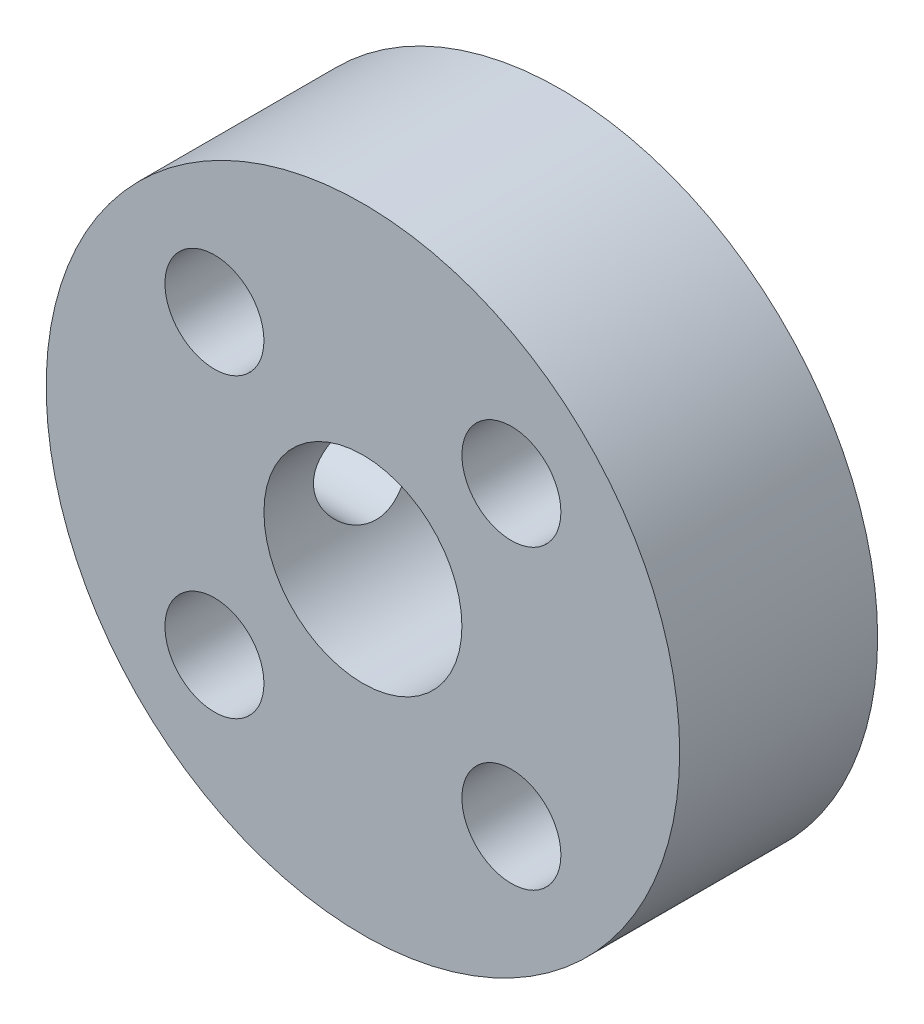
from build123d import *

# Parameters (mm, degrees)
SKETCH1_R           = 20.32
SKETCH1_R_2         = 3.175
SKETCH1_R_3         = 6.35
BOSS_EXTRUDE1_DEPTH = 12.7
SKETCH2_R           = 3.175
CUT_EXTRUDE1_DEPTH  = 21.32


with BuildPart() as part:
    # Sketch1 → Boss-Extrude1 (new body)
    with BuildSketch(Plane.XY):
        Circle(SKETCH1_R)
        with Locations((-9.525, -9.525)):
            Circle(SKETCH1_R_2, mode=Mode.SUBTRACT)
        with Locations((9.525, -9.525)):
            Circle(SKETCH1_R_2, mode=Mode.SUBTRACT)
        with Locations((9.525, 9.525)):
            Circle(SKETCH1_R_2, mode=Mode.SUBTRACT)
        with Locations((-9.525, 9.525)):
            Circle(SKETCH1_R_2, mode=Mode.SUBTRACT)
        Circle(SKETCH1_R_3, mode=Mode.SUBTRACT)
    extrude(amount=BOSS_EXTRUDE1_DEPTH)

    # Sketch2 → Cut-Extrude1 (cut, through all)
    with BuildSketch(Plane(origin=(0, 0, 0), x_dir=(0, 0, -1), z_dir=(1, 0, 0))):
        with Locations((-6.35, 0)):
            Circle(SKETCH2_R)
    extrude(amount=-CUT_EXTRUDE1_DEPTH, mode=Mode.SUBTRACT)


solid = part.part
